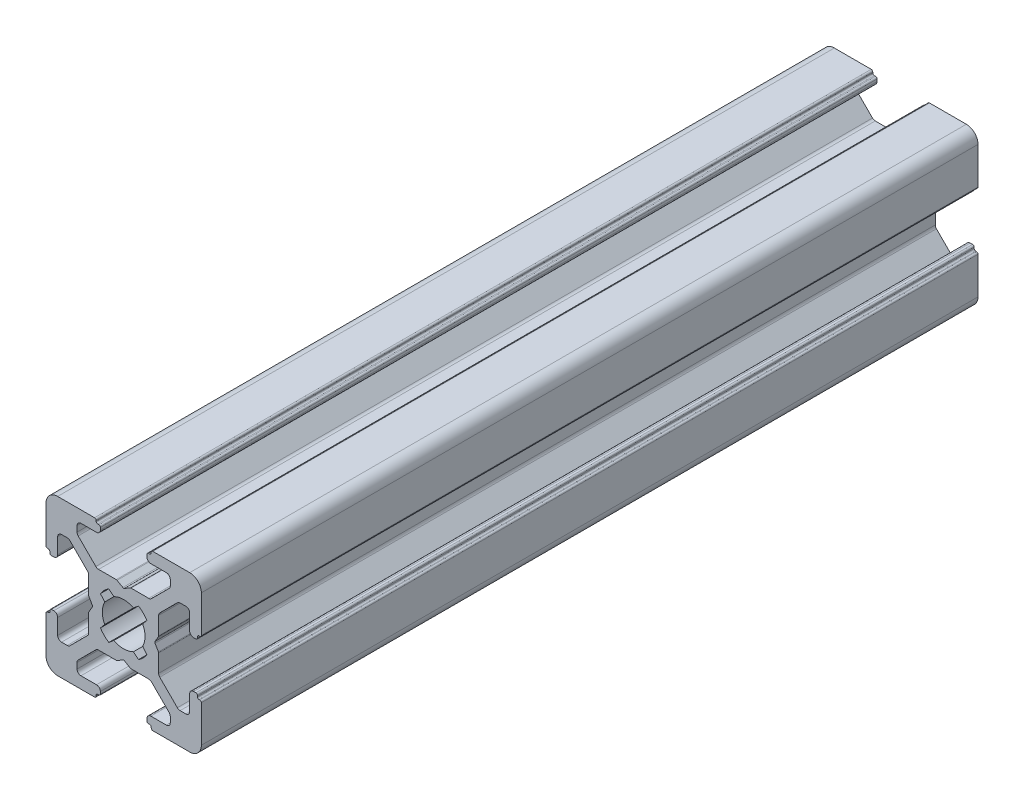
from build123d import *

# Parameters (mm, degrees)
EXTRUDE1_DEPTH = 100


with BuildPart() as part:
    # Sketch1 → Extrude1 (new body)
    with BuildSketch(Plane.XY):
        with BuildLine():
            Line((-3.5, 8.499999673), (-5.500000686, 8.499999673))
            ThreePointArc((-5.500000686, 8.499999673), (-5.853554077, 8.353553064), (-6.000000686, 7.999999673))
            Line((-6.000000686, 7.999999673), (-6.000000686, 7.267766626))
            ThreePointArc((-6.000000686, 7.267766626), (-5.961940448, 7.076424899), (-5.853554059, 6.914213219))
            Line((-5.853554059, 6.914213219), (-3.585787212, 4.646446592))
            ThreePointArc((-3.585787212, 4.646446592), (-3.423575544, 4.538060229), (-3.232233839, 4.5))
            Line((-3.232233839, 4.5), (-0.953590312, 4.5))
            ThreePointArc((-0.953590312, 4.5), (-0.901826505, 4.493185166), (-0.853590316, 4.473205083))
            Line((-0.853590316, 4.473205083), (-0.100000045, 4.038119562))
            ThreePointArc((-0.100000045, 4.038119562), (0, 4.011324632), (0.100000045, 4.038119562))
            Line((0.100000045, 4.038119562), (0.853590316, 4.473205083))
            ThreePointArc((0.853590316, 4.473205083), (0.901826505, 4.493185166), (0.953590312, 4.5))
            Line((0.953590312, 4.5), (3.232233839, 4.5))
            ThreePointArc((3.232233839, 4.5), (3.423575544, 4.538060229), (3.585787212, 4.646446592))
            Line((3.585787212, 4.646446592), (5.853554059, 6.914213219))
            ThreePointArc((5.853554059, 6.914213219), (5.961940448, 7.076424899), (6.000000686, 7.267766626))
            Line((6.000000686, 7.267766626), (6.000000686, 7.999999673))
            ThreePointArc((6.000000686, 7.999999673), (5.853554077, 8.353553064), (5.500000686, 8.499999673))
            Line((5.500000686, 8.499999673), (3.5, 8.499999673))
            ThreePointArc((3.5, 8.499999673), (3.146446609, 8.646446283), (3, 8.999999673))
            Line((3, 8.999999673), (3, 9.3))
            ThreePointArc((3, 9.3), (3.058578644, 9.441421356), (3.2, 9.5))
            Line((3.2, 9.5), (3.350000228, 9.5))
            ThreePointArc((3.350000228, 9.5), (3.491421584, 9.558578644), (3.550000228, 9.7))
            Line((3.550000228, 9.7), (3.550000228, 9.8))
            ThreePointArc((3.550000228, 9.8), (3.608578871, 9.941421356), (3.750000228, 10))
            Line((3.750000228, 10), (8.5, 10))
            ThreePointArc((8.5, 10), (9.560660172, 9.560660172), (10, 8.5))
            Line((10, 8.5), (10, 3.749999605))
            ThreePointArc((10, 3.749999605), (9.941421356, 3.608578248), (9.8, 3.549999605))
            Line((9.8, 3.549999605), (9.699999732, 3.549999605))
            ThreePointArc((9.699999732, 3.549999605), (9.558578376, 3.491420961), (9.499999732, 3.349999605))
            Line((9.499999732, 3.349999605), (9.499999732, 3.2))
            ThreePointArc((9.499999732, 3.2), (9.441421088, 3.058578644), (9.299999732, 3))
            Line((9.299999732, 3), (8.999999732, 3))
            ThreePointArc((8.999999732, 3), (8.646446341, 3.146446609), (8.499999732, 3.5))
            Line((8.499999732, 3.5), (8.499999732, 5.499999605))
            ThreePointArc((8.499999732, 5.499999605), (8.353553123, 5.853552995), (7.999999732, 5.999999605))
            Line((7.999999732, 5.999999605), (7.267766685, 5.999999605))
            ThreePointArc((7.267766685, 5.999999605), (7.076424969, 5.961939371), (6.914213294, 5.853552995))
            Line((6.914213294, 5.853552995), (4.646446398, 3.585786099))
            ThreePointArc((4.646446398, 3.585786099), (4.538060023, 3.423574425), (4.499999789, 3.232232708))
            Line((4.499999789, 3.232232708), (4.499999789, 0.953589302))
            ThreePointArc((4.499999789, 0.953589302), (4.493184953, 0.90182549), (4.473204867, 0.853589297))
            Line((4.473204867, 0.853589297), (4.038119841, 0.099999969))
            ThreePointArc((4.038119841, 0.099999969), (4.011324929, 0), (4.038119841, -0.099999969))
            Line((4.038119841, -0.099999969), (4.473204867, -0.853589297))
            ThreePointArc((4.473204867, -0.853589297), (4.493184953, -0.90182549), (4.499999789, -0.953589302))
            Line((4.499999789, -0.953589302), (4.499999789, -3.232232708))
            ThreePointArc((4.499999789, -3.232232708), (4.538060023, -3.423574425), (4.646446398, -3.585786099))
            Line((4.646446398, -3.585786099), (6.914213294, -5.853552995))
            ThreePointArc((6.914213294, -5.853552995), (7.076424969, -5.961939371), (7.267766685, -5.999999605))
            Line((7.267766685, -5.999999605), (7.999999732, -5.999999605))
            ThreePointArc((7.999999732, -5.999999605), (8.353553123, -5.853552995), (8.499999732, -5.499999605))
            Line((8.499999732, -5.499999605), (8.499999732, -3.5))
            ThreePointArc((8.499999732, -3.5), (8.646446341, -3.146446609), (8.999999732, -3))
            Line((8.999999732, -3), (9.299999732, -3))
            ThreePointArc((9.299999732, -3), (9.441421088, -3.058578644), (9.499999732, -3.2))
            Line((9.499999732, -3.2), (9.499999732, -3.349999605))
            ThreePointArc((9.499999732, -3.349999605), (9.558578376, -3.491420961), (9.699999732, -3.549999605))
            Line((9.699999732, -3.549999605), (9.8, -3.549999605))
            ThreePointArc((9.8, -3.549999605), (9.941421356, -3.608578248), (10, -3.749999605))
            Line((10, -3.749999605), (10, -8.5))
            ThreePointArc((10, -8.5), (9.560660172, -9.560660172), (8.5, -10))
            Line((8.5, -10), (3.750000228, -10))
            ThreePointArc((3.750000228, -10), (3.608578871, -9.941421356), (3.550000228, -9.8))
            Line((3.550000228, -9.8), (3.550000228, -9.7))
            ThreePointArc((3.550000228, -9.7), (3.491421584, -9.558578644), (3.350000228, -9.5))
            Line((3.350000228, -9.5), (3.2, -9.5))
            ThreePointArc((3.2, -9.5), (3.058578644, -9.441421356), (3, -9.3))
            Line((3, -9.3), (3, -8.999999673))
            ThreePointArc((3, -8.999999673), (3.146446609, -8.646446283), (3.5, -8.499999673))
            Line((3.5, -8.499999673), (5.500000686, -8.499999673))
            ThreePointArc((5.500000686, -8.499999673), (5.853554077, -8.353553064), (6.000000686, -7.999999673))
            Line((6.000000686, -7.999999673), (6.000000686, -7.267766626))
            ThreePointArc((6.000000686, -7.267766626), (5.961940448, -7.076424899), (5.853554059, -6.914213219))
            Line((5.853554059, -6.914213219), (3.585787212, -4.646446592))
            ThreePointArc((3.585787212, -4.646446592), (3.423575544, -4.538060229), (3.232233839, -4.5))
            Line((3.232233839, -4.5), (0.953590312, -4.5))
            ThreePointArc((0.953590312, -4.5), (0.901826505, -4.493185166), (0.853590316, -4.473205083))
            Line((0.853590316, -4.473205083), (0.100000045, -4.038119562))
            ThreePointArc((0.100000045, -4.038119562), (0, -4.011324632), (-0.100000045, -4.038119562))
            Line((-0.100000045, -4.038119562), (-0.853590316, -4.473205083))
            ThreePointArc((-0.853590316, -4.473205083), (-0.901826505, -4.493185166), (-0.953590312, -4.5))
            Line((-0.953590312, -4.5), (-3.232233839, -4.5))
            ThreePointArc((-3.232233839, -4.5), (-3.423575544, -4.538060229), (-3.585787212, -4.646446592))
            Line((-3.585787212, -4.646446592), (-5.853554059, -6.914213219))
            ThreePointArc((-5.853554059, -6.914213219), (-5.961940448, -7.076424899), (-6.000000686, -7.267766626))
            Line((-6.000000686, -7.267766626), (-6.000000686, -7.999999673))
            ThreePointArc((-6.000000686, -7.999999673), (-5.853554077, -8.353553064), (-5.500000686, -8.499999673))
            Line((-5.500000686, -8.499999673), (-3.5, -8.499999673))
            ThreePointArc((-3.5, -8.499999673), (-3.146446609, -8.646446283), (-3, -8.999999673))
            Line((-3, -8.999999673), (-3, -9.3))
            ThreePointArc((-3, -9.3), (-3.058578644, -9.441421356), (-3.2, -9.5))
            Line((-3.2, -9.5), (-3.350000228, -9.5))
            ThreePointArc((-3.350000228, -9.5), (-3.491421584, -9.558578644), (-3.550000228, -9.7))
            Line((-3.550000228, -9.7), (-3.550000228, -9.8))
            ThreePointArc((-3.550000228, -9.8), (-3.608578871, -9.941421356), (-3.750000228, -10))
            Line((-3.750000228, -10), (-8.5, -10))
            ThreePointArc((-8.5, -10), (-9.560660172, -9.560660172), (-10, -8.5))
            Line((-10, -8.5), (-10, -3.749999605))
            ThreePointArc((-10, -3.749999605), (-9.941421356, -3.608578248), (-9.8, -3.549999605))
            Line((-9.8, -3.549999605), (-9.699999732, -3.549999605))
            ThreePointArc((-9.699999732, -3.549999605), (-9.558578376, -3.491420961), (-9.499999732, -3.349999605))
            Line((-9.499999732, -3.349999605), (-9.499999732, -3.2))
            ThreePointArc((-9.499999732, -3.2), (-9.441421088, -3.058578644), (-9.299999732, -3))
            Line((-9.299999732, -3), (-8.999999732, -3))
            ThreePointArc((-8.999999732, -3), (-8.646446341, -3.146446609), (-8.499999732, -3.5))
            Line((-8.499999732, -3.5), (-8.499999732, -5.499999605))
            ThreePointArc((-8.499999732, -5.499999605), (-8.353553123, -5.853552995), (-7.999999732, -5.999999605))
            Line((-7.999999732, -5.999999605), (-7.267766685, -5.999999605))
            ThreePointArc((-7.267766685, -5.999999605), (-7.076424969, -5.961939371), (-6.914213294, -5.853552995))
            Line((-6.914213294, -5.853552995), (-4.646446398, -3.585786099))
            ThreePointArc((-4.646446398, -3.585786099), (-4.538060023, -3.423574425), (-4.499999789, -3.232232708))
            Line((-4.499999789, -3.232232708), (-4.499999789, -0.953589302))
            ThreePointArc((-4.499999789, -0.953589302), (-4.493184953, -0.90182549), (-4.473204867, -0.853589297))
            Line((-4.473204867, -0.853589297), (-4.038119841, -0.099999969))
            ThreePointArc((-4.038119841, -0.099999969), (-4.011324929, 0), (-4.038119841, 0.099999969))
            Line((-4.038119841, 0.099999969), (-4.473204867, 0.853589297))
            ThreePointArc((-4.473204867, 0.853589297), (-4.493184953, 0.90182549), (-4.499999789, 0.953589302))
            Line((-4.499999789, 0.953589302), (-4.499999789, 3.232232708))
            ThreePointArc((-4.499999789, 3.232232708), (-4.538060023, 3.423574425), (-4.646446398, 3.585786099))
            Line((-4.646446398, 3.585786099), (-6.914213294, 5.853552995))
            ThreePointArc((-6.914213294, 5.853552995), (-7.076424969, 5.961939371), (-7.267766685, 5.999999605))
            Line((-7.267766685, 5.999999605), (-7.999999732, 5.999999605))
            ThreePointArc((-7.999999732, 5.999999605), (-8.353553123, 5.853552995), (-8.499999732, 5.499999605))
            Line((-8.499999732, 5.499999605), (-8.499999732, 3.5))
            ThreePointArc((-8.499999732, 3.5), (-8.646446341, 3.146446609), (-8.999999732, 3))
            Line((-8.999999732, 3), (-9.299999732, 3))
            ThreePointArc((-9.299999732, 3), (-9.441421088, 3.058578644), (-9.499999732, 3.2))
            Line((-9.499999732, 3.2), (-9.499999732, 3.349999605))
            ThreePointArc((-9.499999732, 3.349999605), (-9.558578376, 3.491420961), (-9.699999732, 3.549999605))
            Line((-9.699999732, 3.549999605), (-9.8, 3.549999605))
            ThreePointArc((-9.8, 3.549999605), (-9.941421356, 3.608578248), (-10, 3.749999605))
            Line((-10, 3.749999605), (-10, 8.5))
            ThreePointArc((-10, 8.5), (-9.560660172, 9.560660172), (-8.5, 10))
            Line((-8.5, 10), (-3.750000228, 10))
            ThreePointArc((-3.750000228, 10), (-3.608578871, 9.941421356), (-3.550000228, 9.8))
            Line((-3.550000228, 9.8), (-3.550000228, 9.7))
            ThreePointArc((-3.550000228, 9.7), (-3.491421584, 9.558578644), (-3.350000228, 9.5))
            Line((-3.350000228, 9.5), (-3.2, 9.5))
            ThreePointArc((-3.2, 9.5), (-3.058578644, 9.441421356), (-3, 9.3))
            Line((-3, 9.3), (-3, 8.999999673))
            ThreePointArc((-3, 8.999999673), (-3.146446609, 8.646446283), (-3.5, 8.499999673))
        make_face()
        with BuildLine():
            Line((-1.258185436, 2.445295362), (-1.91389502, 2.989640962))
            ThreePointArc((-1.91389502, 2.989640962), (-2.511737261, 2.508410485), (-2.992174953, 1.909930962))
            Line((-2.992174953, 1.909930962), (-2.445295423, 1.258185317))
            ThreePointArc((-2.445295423, 1.258185317), (-2.75, 0), (-2.445295423, -1.258185317))
            Line((-2.445295423, -1.258185317), (-2.992174953, -1.909930962))
            ThreePointArc((-2.992174953, -1.909930962), (-2.511737261, -2.508410485), (-1.91389502, -2.989640962))
            Line((-1.91389502, -2.989640962), (-1.258185436, -2.445295362))
            ThreePointArc((-1.258185436, -2.445295362), (0, -2.75), (1.258185436, -2.445295362))
            Line((1.258185436, -2.445295362), (1.91389502, -2.989640962))
            ThreePointArc((1.91389502, -2.989640962), (2.511737261, -2.508410485), (2.992174953, -1.909930962))
            Line((2.992174953, -1.909930962), (2.445295423, -1.258185317))
            ThreePointArc((2.445295423, -1.258185317), (2.75, 0), (2.445295423, 1.258185317))
            Line((2.445295423, 1.258185317), (2.992174953, 1.909930962))
            ThreePointArc((2.992174953, 1.909930962), (2.511737261, 2.508410485), (1.91389502, 2.989640962))
            Line((1.91389502, 2.989640962), (1.258185436, 2.445295362))
            ThreePointArc((1.258185436, 2.445295362), (0, 2.75), (-1.258185436, 2.445295362))
        make_face(mode=Mode.SUBTRACT)
    extrude(amount=EXTRUDE1_DEPTH)


solid = part.part
